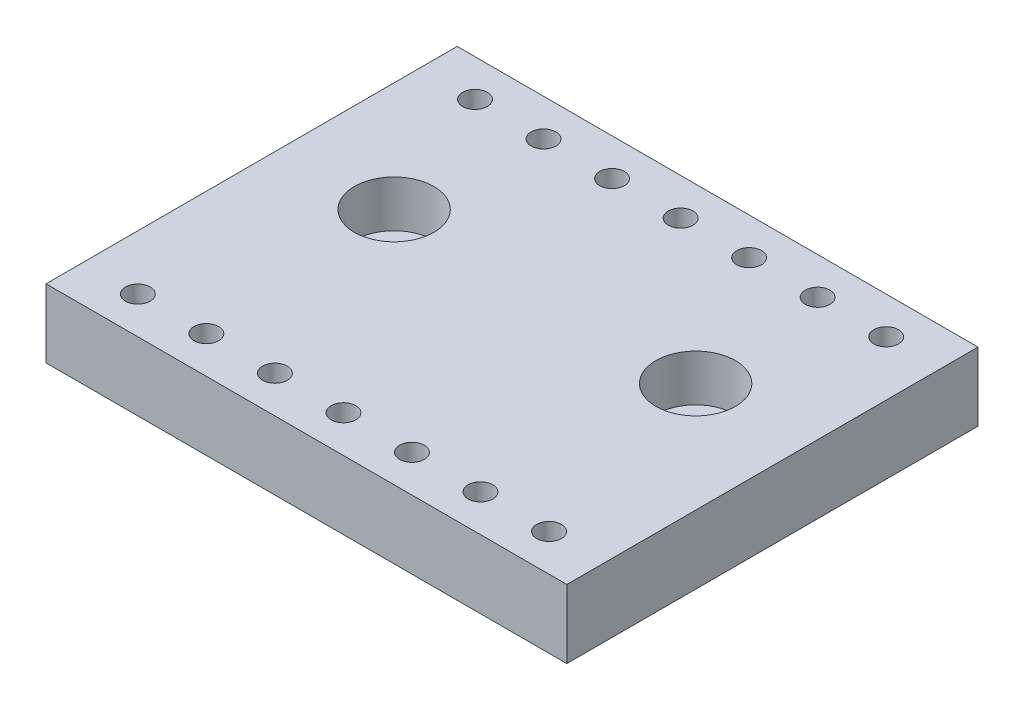
from build123d import *

# Parameters (mm, degrees)
SKETCH1_W           = 48.26
SKETCH1_H           = 38.1
BOSS_EXTRUDE1_DEPTH = 6.35
SKETCH2_R           = 3.683
CUT_EXTRUDE1_DEPTH  = 4.318
SKETCH3_R           = 2.159
CUT_EXTRUDE2_DEPTH  = 4.318
SKETCH4_R           = 1.143
CUT_EXTRUDE3_DEPTH  = 9.398
LPATTERN1_COUNT     = 7
LPATTERN1_PITCH     = 6.35


with BuildPart() as part:
    # Sketch1 → Boss-Extrude1 (new body)
    with BuildSketch(Plane(origin=(0, 0, 0), x_dir=(1, 0, 0), z_dir=(0, 1, 0))):
        Rectangle(SKETCH1_W, SKETCH1_H)
    extrude(amount=-BOSS_EXTRUDE1_DEPTH)

    # Sketch2 → Cut-Extrude1 (cut)
    with BuildSketch(Plane(origin=(0, 0, 0), x_dir=(1, 0, 0), z_dir=(0, 1, 0))):
        with Locations((-13.97, 3.048)):
            Circle(SKETCH2_R)
    cut_extrude1 = extrude(amount=-CUT_EXTRUDE1_DEPTH, mode=Mode.SUBTRACT)

    # Sketch3 → Cut-Extrude2 (cut)
    with BuildSketch(Plane(origin=(0, -4.318, 0), x_dir=(1, 0, 0), z_dir=(0, 1, 0))):
        with Locations((-13.97, 3.048)):
            Circle(SKETCH3_R)
    cut_extrude2 = extrude(amount=-CUT_EXTRUDE2_DEPTH, mode=Mode.SUBTRACT)

    # Sketch4 → Cut-Extrude3 (cut)
    with BuildSketch(Plane(origin=(0, 0, 0), x_dir=(1, 0, 0), z_dir=(0, 1, 0))):
        with Locations((-19.05, 15.621)):
            Circle(SKETCH4_R)
        with Locations((-19.05, -15.621)):
            Circle(SKETCH4_R)
    cut_extrude3 = extrude(amount=-CUT_EXTRUDE3_DEPTH, mode=Mode.SUBTRACT)

    # LPattern1: Cut-Extrude3 ×7
    with Locations(*[(i * LPATTERN1_PITCH, 0, 0) for i in range(1, LPATTERN1_COUNT)]):
        add(cut_extrude3, mode=Mode.SUBTRACT)

    # Mirror1: Cut-Extrude1, Cut-Extrude2 across plane
    add(cut_extrude1.mirror(Plane(origin=(0, 0, 0), x_dir=(0, 0, 1), z_dir=(1, 0, 0))), mode=Mode.SUBTRACT)
    add(cut_extrude2.mirror(Plane(origin=(0, 0, 0), x_dir=(0, 0, 1), z_dir=(1, 0, 0))), mode=Mode.SUBTRACT)


solid = part.part
